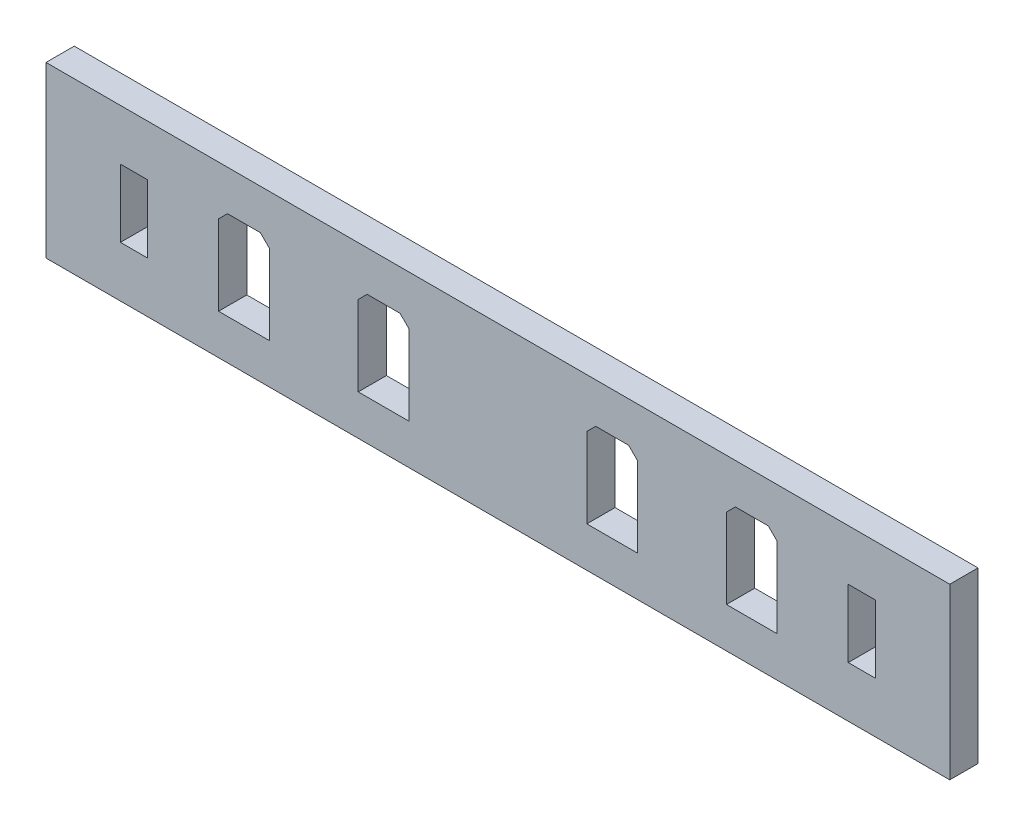
from build123d import *

# Parameters (mm, degrees)
SKETCH1_W           = 101.6
SKETCH1_H           = 19.05
BOSS_EXTRUDE1_DEPTH = 3.175
SKETCH2_W           = 3.048
SKETCH2_H           = 7.62
CUT_EXTRUDE1_DEPTH  = 4.175
SKETCH3_W           = 5.7
SKETCH3_H           = 10
CUT_EXTRUDE2_DEPTH  = 4.175
CHAMFER1_SIZE       = 1


with BuildPart() as part:
    # Sketch1 → Boss-Extrude1 (new body)
    with BuildSketch(Plane.XY):
        with Locations((50.8, 9.525)):
            Rectangle(SKETCH1_W, SKETCH1_H)
    extrude(amount=BOSS_EXTRUDE1_DEPTH)

    # Sketch2 → Cut-Extrude1 (cut, through all)
    with BuildSketch(Plane.XY.offset(3.175)):
        with Locations((9.892117884, 9.525)):
            Rectangle(SKETCH2_W, SKETCH2_H)
        with Locations((91.707882116, 9.525)):
            Rectangle(SKETCH2_W, SKETCH2_H)
    extrude(amount=-CUT_EXTRUDE1_DEPTH, mode=Mode.SUBTRACT)

    # Sketch3 → Cut-Extrude2 (cut, through all)
    with BuildSketch(Plane.XY.offset(3.175)):
        with Locations((37.95, 9.525)):
            Rectangle(SKETCH3_W, SKETCH3_H)
        with Locations((63.65, 9.525)):
            Rectangle(SKETCH3_W, SKETCH3_H)
        with Locations((79.35, 9.525)):
            Rectangle(SKETCH3_W, SKETCH3_H)
        with Locations((22.25, 9.525)):
            Rectangle(SKETCH3_W, SKETCH3_H)
    extrude(amount=-CUT_EXTRUDE2_DEPTH, mode=Mode.SUBTRACT)

    # Chamfer1
    chamfer1_edges = [part.edges().sort_by_distance(p)[0] for p in [
        (76.5, 14.525, 1.5875),
        (82.2, 14.525, 1.5875),
        (19.4, 14.525, 1.5875),
        (25.1, 14.525, 1.5875),
        (60.8, 14.525, 1.5875),
        (66.5, 14.525, 1.5875),
        (35.1, 14.525, 1.5875),
        (40.8, 14.525, 1.5875),
    ]]
    chamfer(chamfer1_edges, length=CHAMFER1_SIZE)


solid = part.part
